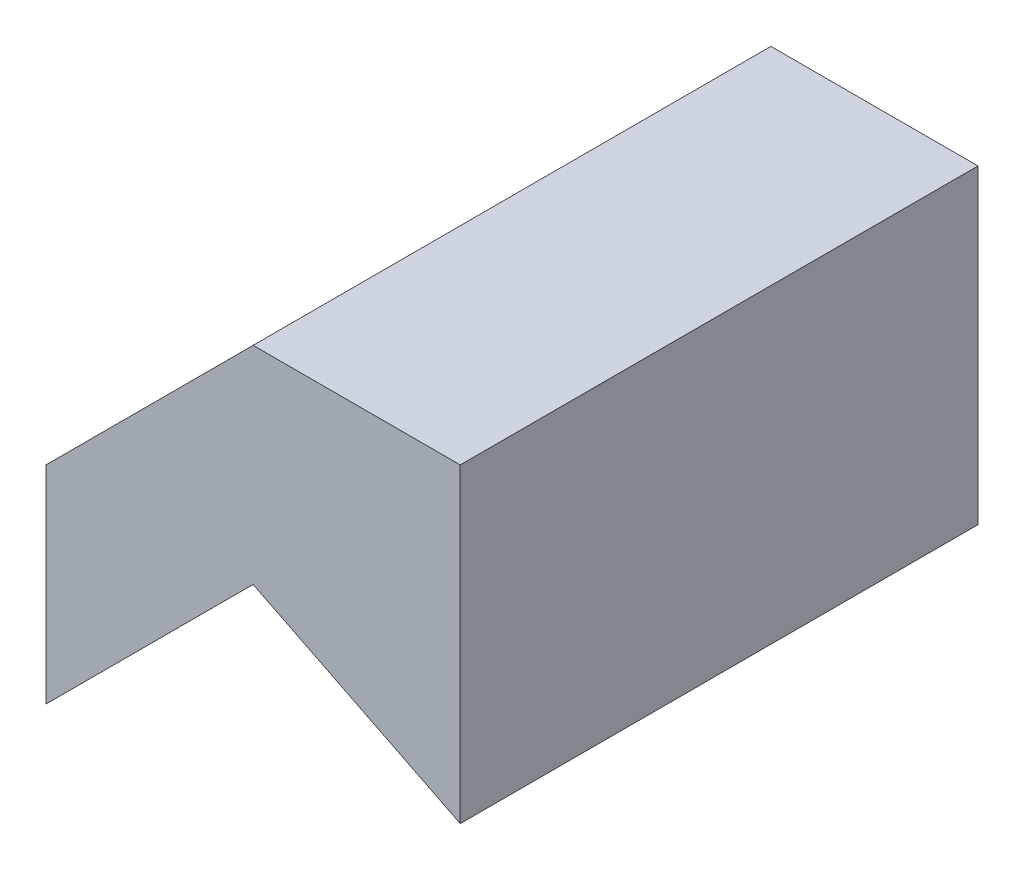
from build123d import *

# Parameters (mm, degrees)
BOSS_EXTRUDE1_DEPTH = 25


with BuildPart() as part:
    # Sketch1 → Boss-Extrude1 (new body)
    with BuildSketch(Plane.XY):
        Polygon((-10, 0), (0, 10), (10, 10), (10, -5), (0, 0), (-10, -10), align=None)
    extrude(amount=BOSS_EXTRUDE1_DEPTH)


solid = part.part
